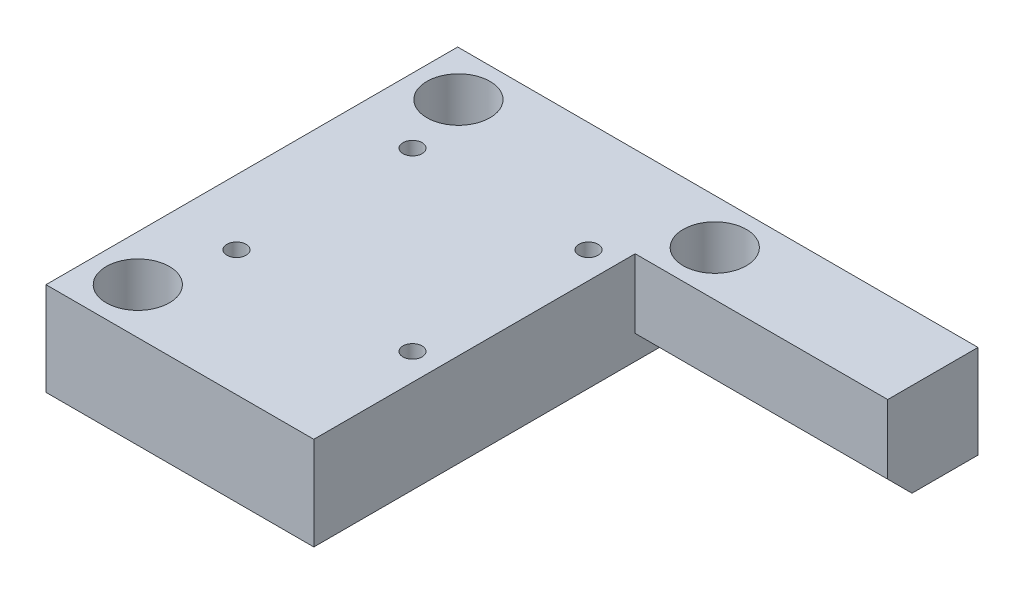
from build123d import *

# Parameters (mm, degrees)
SKETCH1_W           = 68
SKETCH1_H           = 12.192
BOSS_EXTRUDE1_DEPTH = 11.8
SKETCH2_R           = 2.25
CUT_EXTRUDE1_DEPTH  = 13.192
SKETCH3_R           = 4.125
CUT_EXTRUDE2_DEPTH  = 7
SKETCH4_W           = 35
SKETCH4_H           = 12.192
BOSS_EXTRUDE2_DEPTH = 42
SKETCH5_R           = 2.25
CUT_EXTRUDE3_DEPTH  = 13.192
SKETCH6_R           = 4.125
CUT_EXTRUDE4_DEPTH  = 7
CUT_EXTRUDE5_REACH  = 14.192
SKETCH7_R           = 1.25
CHAMFER1_SIZE       = 3.175


with BuildPart() as part:
    # Sketch1 → Boss-Extrude1 (new body)
    with BuildSketch(Plane.XY):
        with Locations((34, -6.096)):
            Rectangle(SKETCH1_W, SKETCH1_H)
    extrude(amount=BOSS_EXTRUDE1_DEPTH)

    # Sketch2 → Cut-Extrude1 (cut, through all)
    with BuildSketch(Plane(origin=(0, 0, 0), x_dir=(1, 0, 0), z_dir=(0, 1, 0))):
        with Locations((39.5, -5.9)):
            Circle(SKETCH2_R)
        with Locations((6, -5.9)):
            Circle(SKETCH2_R)
    extrude(amount=-CUT_EXTRUDE1_DEPTH, mode=Mode.SUBTRACT)

    # Sketch3 → Cut-Extrude2 (cut)
    with BuildSketch(Plane(origin=(0, 0, 0), x_dir=(1, 0, 0), z_dir=(0, 1, 0))):
        with Locations((39.5, -5.9)):
            Circle(SKETCH3_R)
        with Locations((6, -5.9)):
            Circle(SKETCH3_R)
    extrude(amount=-CUT_EXTRUDE2_DEPTH, mode=Mode.SUBTRACT)

    # Sketch4 → Boss-Extrude2 (add)
    with BuildSketch(Plane.XY.offset(11.8)):
        with Locations((17.5, -6.096)):
            Rectangle(SKETCH4_W, SKETCH4_H)
    extrude(amount=BOSS_EXTRUDE2_DEPTH)

    # Sketch5 → Cut-Extrude3 (cut, through all)
    with BuildSketch(Plane(origin=(0, 0, 0), x_dir=(1, 0, 0), z_dir=(0, 1, 0))):
        with Locations((6, -47.8)):
            Circle(SKETCH5_R)
    extrude(amount=-CUT_EXTRUDE3_DEPTH, mode=Mode.SUBTRACT)

    # Sketch6 → Cut-Extrude4 (cut)
    with BuildSketch(Plane(origin=(0, 0, 0), x_dir=(1, 0, 0), z_dir=(0, 1, 0))):
        with Locations((6, -47.8)):
            Circle(SKETCH6_R)
    extrude(amount=-CUT_EXTRUDE4_DEPTH, mode=Mode.SUBTRACT)

    # Sketch7 → Cut-Extrude5 (cut, up to next)
    with BuildSketch(Plane(origin=(0, 0, 0), x_dir=(1, 0, 0), z_dir=(0, 1, 0)), mode=Mode.PRIVATE) as cut_extrude5_sk1:
        with Locations((8.5, -14.400241512)):
            Circle(SKETCH7_R)
    cut_extrude5_tool1 = extrude(cut_extrude5_sk1.sketch, amount=-CUT_EXTRUDE5_REACH, mode=Mode.PRIVATE) & part.part
    add(cut_extrude5_tool1.solids().sort_by_distance((8.5, 0, 14.400242))[0], mode=Mode.SUBTRACT)
    # Sketch7 → Cut-Extrude5 (cut, up to next)
    with BuildSketch(Plane(origin=(0, 0, 0), x_dir=(1, 0, 0), z_dir=(0, 1, 0)), mode=Mode.PRIVATE) as cut_extrude5_sk2:
        with Locations((8.497816512, -37.402425)):
            Circle(SKETCH7_R)
    cut_extrude5_tool2 = extrude(cut_extrude5_sk2.sketch, amount=-CUT_EXTRUDE5_REACH, mode=Mode.PRIVATE) & part.part
    add(cut_extrude5_tool2.solids().sort_by_distance((8.497817, 0, 37.402425))[0], mode=Mode.SUBTRACT)
    # Sketch7 → Cut-Extrude5 (cut, up to next)
    with BuildSketch(Plane(origin=(0, 0, 0), x_dir=(1, 0, 0), z_dir=(0, 1, 0)), mode=Mode.PRIVATE) as cut_extrude5_sk3:
        with Locations((31.5, -37.404608488)):
            Circle(SKETCH7_R)
    cut_extrude5_tool3 = extrude(cut_extrude5_sk3.sketch, amount=-CUT_EXTRUDE5_REACH, mode=Mode.PRIVATE) & part.part
    add(cut_extrude5_tool3.solids().sort_by_distance((31.5, 0, 37.404608))[0], mode=Mode.SUBTRACT)
    # Sketch7 → Cut-Extrude5 (cut, up to next)
    with BuildSketch(Plane(origin=(0, 0, 0), x_dir=(1, 0, 0), z_dir=(0, 1, 0)), mode=Mode.PRIVATE) as cut_extrude5_sk4:
        with Locations((31.502183488, -14.402425)):
            Circle(SKETCH7_R)
    cut_extrude5_tool4 = extrude(cut_extrude5_sk4.sketch, amount=-CUT_EXTRUDE5_REACH, mode=Mode.PRIVATE) & part.part
    add(cut_extrude5_tool4.solids().sort_by_distance((31.502183, 0, 14.402425))[0], mode=Mode.SUBTRACT)

    # Chamfer1
    chamfer1_edges = [part.edges().sort_by_distance(p)[0] for p in [
        (51.5, -12.192, 11.8),
    ]]
    chamfer(chamfer1_edges, length=CHAMFER1_SIZE)


solid = part.part
